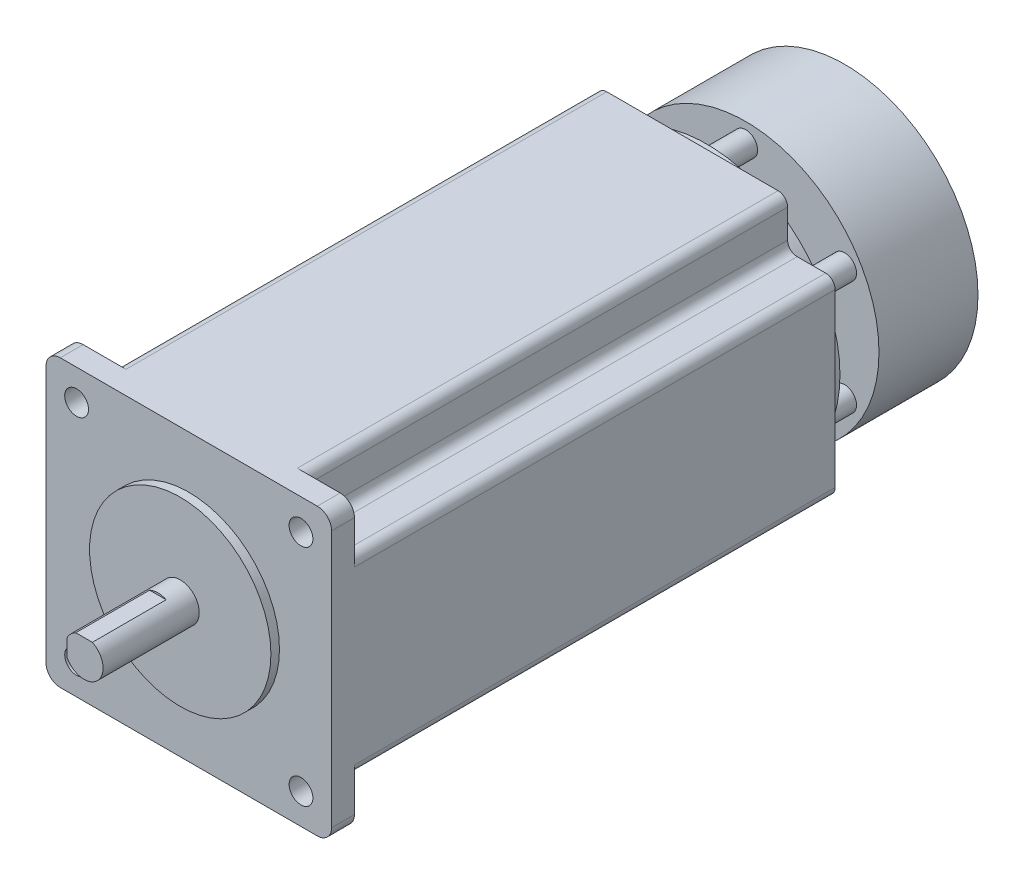
from build123d import *

# Parameters (mm, degrees)
SKETCH1_R           = 2.5
BOSS_EXTRUDE1_DEPTH = 4.8
BOSS_EXTRUDE2_DEPTH = 101
SKETCH4_R           = 19.05
BOSS_EXTRUDE3_DEPTH = 1.8
SKETCH5_R           = 4
BOSS_EXTRUDE4_DEPTH = 20.2
CUT_EXTRUDE1_DEPTH  = 15.5
SKETCH8_R           = 28
BOSS_EXTRUDE5_DEPTH = 3
SKETCH9_R           = 2.5
BOSS_EXTRUDE6_DEPTH = 8.2
SKETCH10_R          = 28
BOSS_EXTRUDE7_DEPTH = 20.8
SKETCH11_W          = 21
SKETCH11_H          = 9
BOSS_EXTRUDE8_DEPTH = 17
CHAMFER1_SIZE       = 1
SKETCH12_R          = 4
BOSS_EXTRUDE9_DEPTH = 29


with BuildPart() as part:
    # Sketch1 → Boss-Extrude1 (new body)
    with BuildSketch(Plane.XY):
        with BuildLine():
            Line((-27, -30), (27, -30))
            ThreePointArc((27, -30), (29.121320344, -29.121320344), (30, -27))
            Line((30, -27), (30, 27))
            ThreePointArc((30, 27), (29.121320344, 29.121320344), (27, 30))
            Line((27, 30), (-27, 30))
            ThreePointArc((-27, 30), (-29.121320344, 29.121320344), (-30, 27))
            Line((-30, 27), (-30, -27))
            ThreePointArc((-30, -27), (-29.121320344, -29.121320344), (-27, -30))
        make_face()
        with Locations((-23.57, 23.57)):
            Circle(SKETCH1_R, mode=Mode.SUBTRACT)
        with Locations((23.57, 23.57)):
            Circle(SKETCH1_R, mode=Mode.SUBTRACT)
        with Locations((23.57, -23.57)):
            Circle(SKETCH1_R, mode=Mode.SUBTRACT)
        with Locations((-23.57, -23.57)):
            Circle(SKETCH1_R, mode=Mode.SUBTRACT)
    extrude(amount=-BOSS_EXTRUDE1_DEPTH)

    # Sketch3 → Boss-Extrude2 (add)
    with BuildSketch(Plane(origin=(0, 0, -4.8), x_dir=(-1, 0, 0), z_dir=(0, 0, -1))):
        with BuildLine():
            Line((18, 30), (-18, 30))
            ThreePointArc((-18, 30), (-19.414213562, 29.414213562), (-20, 28))
            Line((-20, 28), (-20, 22))
            ThreePointArc((-20, 22), (-20.585786438, 20.585786438), (-22, 20))
            Line((-22, 20), (-28, 20))
            ThreePointArc((-28, 20), (-29.414213562, 19.414213562), (-30, 18))
            Line((-30, 18), (-30, -18))
            ThreePointArc((-30, -18), (-29.414213562, -19.414213562), (-28, -20))
            Line((-28, -20), (-22, -20))
            ThreePointArc((-22, -20), (-20.585786438, -20.585786438), (-20, -22))
            Line((-20, -22), (-20, -28))
            ThreePointArc((-20, -28), (-19.414213562, -29.414213562), (-18, -30))
            Line((-18, -30), (18, -30))
            ThreePointArc((18, -30), (19.414213562, -29.414213562), (20, -28))
            Line((20, -28), (20, -22))
            ThreePointArc((20, -22), (20.585786438, -20.585786438), (22, -20))
            Line((22, -20), (28, -20))
            ThreePointArc((28, -20), (29.414213562, -19.414213562), (30, -18))
            Line((30, -18), (30, 18))
            ThreePointArc((30, 18), (29.414213562, 19.414213562), (28, 20))
            Line((28, 20), (22, 20))
            ThreePointArc((22, 20), (20.585786438, 20.585786438), (20, 22))
            Line((20, 22), (20, 28))
            ThreePointArc((20, 28), (19.414213562, 29.414213562), (18, 30))
        make_face()
    extrude(amount=BOSS_EXTRUDE2_DEPTH)

    # Sketch4 → Boss-Extrude3 (add)
    with BuildSketch(Plane.XY):
        Circle(SKETCH4_R)
    extrude(amount=BOSS_EXTRUDE3_DEPTH)

    # Sketch5 → Boss-Extrude4 (add)
    with BuildSketch(Plane.XY.offset(1.8)):
        Circle(SKETCH5_R)
    extrude(amount=BOSS_EXTRUDE4_DEPTH)

    # Sketch7 → Cut-Extrude1 (cut)
    with BuildSketch(Plane.XY.offset(22)):
        with BuildLine():
            Line((-1.743559577, 3.6), (1.743559577, 3.6))
            ThreePointArc((1.743559577, 3.6), (0, 4), (-1.743559577, 3.6))
        make_face()
        with BuildLine():
            Line((-3.6, 1.743559577), (-3.6, -1.743559577))
            ThreePointArc((-3.6, -1.743559577), (-4, 0), (-3.6, 1.743559577))
        make_face()
    extrude(amount=-CUT_EXTRUDE1_DEPTH, mode=Mode.SUBTRACT)

    # Sketch8 → Boss-Extrude5 (add)
    with BuildSketch(Plane(origin=(0, 0, -105.8), x_dir=(-1, 0, 0), z_dir=(0, 0, -1))):
        Circle(SKETCH8_R)
    extrude(amount=BOSS_EXTRUDE5_DEPTH)

    # Sketch9 → Boss-Extrude6 (add)
    with BuildSketch(Plane(origin=(0, 0, -108.8), x_dir=(-1, 0, 0), z_dir=(0, 0, -1))):
        with Locations((0, 24)):
            Circle(SKETCH9_R)
        with Locations((20.784609691, 12)):
            Circle(SKETCH9_R)
        with Locations((20.784609691, -12)):
            Circle(SKETCH9_R)
        with Locations((0, -24)):
            Circle(SKETCH9_R)
        with Locations((-20.784609691, -12)):
            Circle(SKETCH9_R)
        with Locations((-20.784609691, 12)):
            Circle(SKETCH9_R)
    extrude(amount=BOSS_EXTRUDE6_DEPTH)

    # Sketch10 → Boss-Extrude7 (add)
    with BuildSketch(Plane(origin=(0, 0, -117), x_dir=(-1, 0, 0), z_dir=(0, 0, -1))):
        Circle(SKETCH10_R)
    extrude(amount=BOSS_EXTRUDE7_DEPTH)

    # Sketch11 → Boss-Extrude8 (add)
    with BuildSketch(Plane(origin=(0, 0, -105.8), x_dir=(-1, 0, 0), z_dir=(0, 0, -1))):
        with Locations((0, -34.5)):
            Rectangle(SKETCH11_W, SKETCH11_H)
    extrude(amount=-BOSS_EXTRUDE8_DEPTH)

    # Chamfer1
    chamfer1_edges = [part.edges().sort_by_distance(p)[0] for p in [
        (10.5, -39, -97.3),
        (-10.5, -39, -97.3),
    ]]
    chamfer(chamfer1_edges, length=CHAMFER1_SIZE)

    # Sketch12 → Boss-Extrude9 (add)
    with BuildSketch(Plane(origin=(0, 0, -137.8), x_dir=(-1, 0, 0), z_dir=(0, 0, -1))):
        Circle(SKETCH12_R)
    extrude(amount=-BOSS_EXTRUDE9_DEPTH)


solid = part.part
